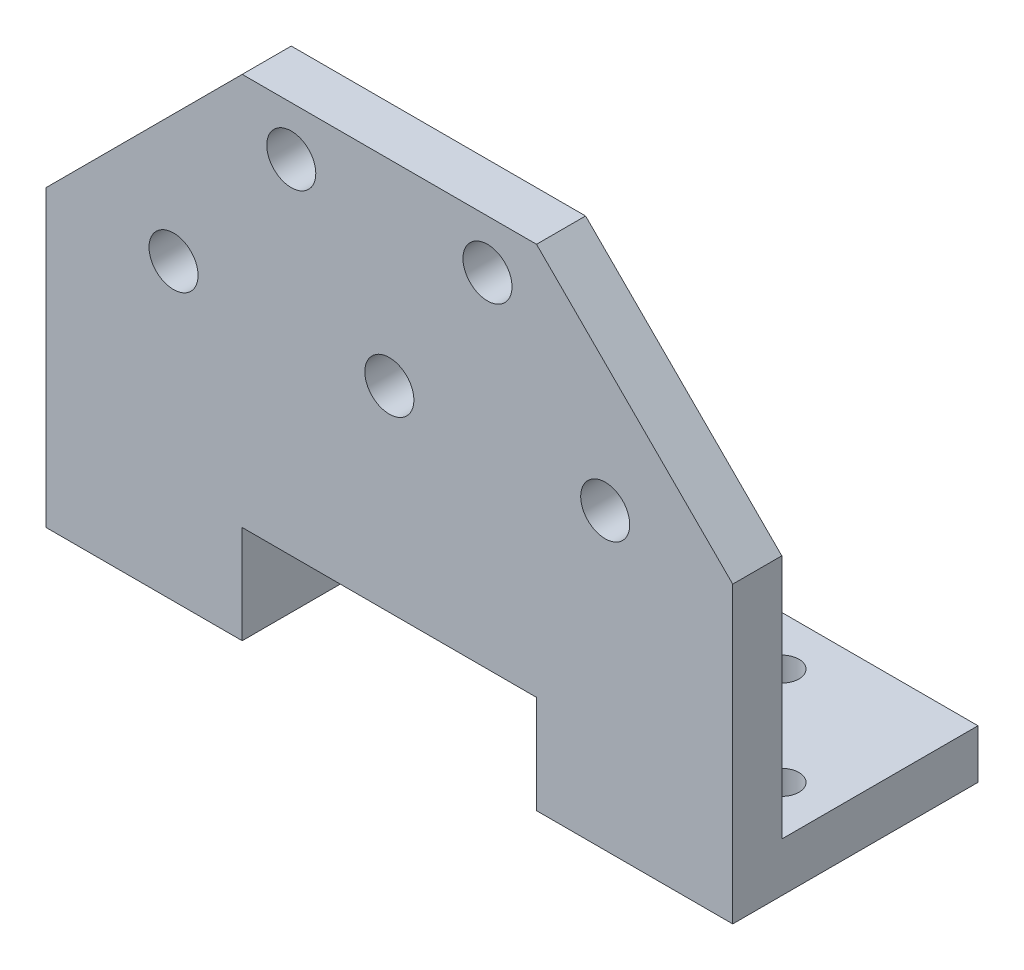
from build123d import *

# Parameters (mm, degrees)
EXTRUDE_1_DEPTH          = 5
SKETCH_3_W               = 20
SKETCH_3_H               = 20
EXTRUDE_2_DEPTH          = 5
SKETCH_4_R               = 1.75
CUT_EXTRUDE_1_DEPTH      = 6
CUT_EXTRUDE_2_DEPTH      = 1
CUT_EXTRUDE_2_DEPTH_BACK = 26
SKETCH_6_R               = 2.5
CUT_EXTRUDE_3_DEPTH      = 6


with BuildPart() as part:
    # ｽｹｯﾁ1 → ﾎﾞｽ - 押し出し1 (new body)
    with BuildSketch(Plane.XY):
        Polygon((-15, 10), (15, 10), (15, 0), (35, 0), (35, 50), (-35, 50), (-35, 0), (-15, 0), align=None)
    extrude(amount=EXTRUDE_1_DEPTH)

    # ｽｹｯﾁ3 → ﾎﾞｽ - 押し出し2 (add)
    with BuildSketch(Plane(origin=(0, 0, 0), x_dir=(1, 0, 0), z_dir=(0, 1, 0))):
        with Locations((-25, 10)):
            Rectangle(SKETCH_3_W, SKETCH_3_H)
        with Locations((25, 10)):
            Rectangle(SKETCH_3_W, SKETCH_3_H)
    extrude(amount=EXTRUDE_2_DEPTH)

    # ｽｹｯﾁ4 → ｶｯﾄ - 押し出し1 (cut, through all)
    with BuildSketch(Plane(origin=(0, 5, 0), x_dir=(1, 0, 0), z_dir=(0, 1, 0))):
        with Locations((-30, 5)):
            Circle(SKETCH_4_R)
        with Locations((-20, 15)):
            Circle(SKETCH_4_R)
        with Locations((20, 15)):
            Circle(SKETCH_4_R)
        with Locations((30, 5)):
            Circle(SKETCH_4_R)
    extrude(amount=-CUT_EXTRUDE_1_DEPTH, mode=Mode.SUBTRACT)

    # ｽｹｯﾁ5 → ｶｯﾄ - 押し出し2 (cut, two sides)
    with BuildSketch(Plane.XY.offset(5)) as cut_extrude_2_sk:
        Polygon((15, 50), (35, 30), (35, 50), align=None)
        Polygon((-35, 30), (-15, 50), (-35, 50), align=None)
    extrude(amount=CUT_EXTRUDE_2_DEPTH, mode=Mode.SUBTRACT)
    extrude(cut_extrude_2_sk.sketch, amount=-CUT_EXTRUDE_2_DEPTH_BACK, mode=Mode.SUBTRACT)

    # ｽｹｯﾁ6 → ｶｯﾄ - 押し出し3 (cut, through all)
    with BuildSketch(Plane(origin=(0, 0, 0), x_dir=(-1, 0, 0), z_dir=(0, 0, -1))):
        with Locations((-22, 30)):
            Circle(SKETCH_6_R)
        with Locations((0, 30)):
            Circle(SKETCH_6_R)
        with Locations((-10, 45)):
            Circle(SKETCH_6_R)
        with Locations((10, 45)):
            Circle(SKETCH_6_R)
        with Locations((22, 30)):
            Circle(SKETCH_6_R)
    extrude(amount=-CUT_EXTRUDE_3_DEPTH, mode=Mode.SUBTRACT)


solid = part.part
